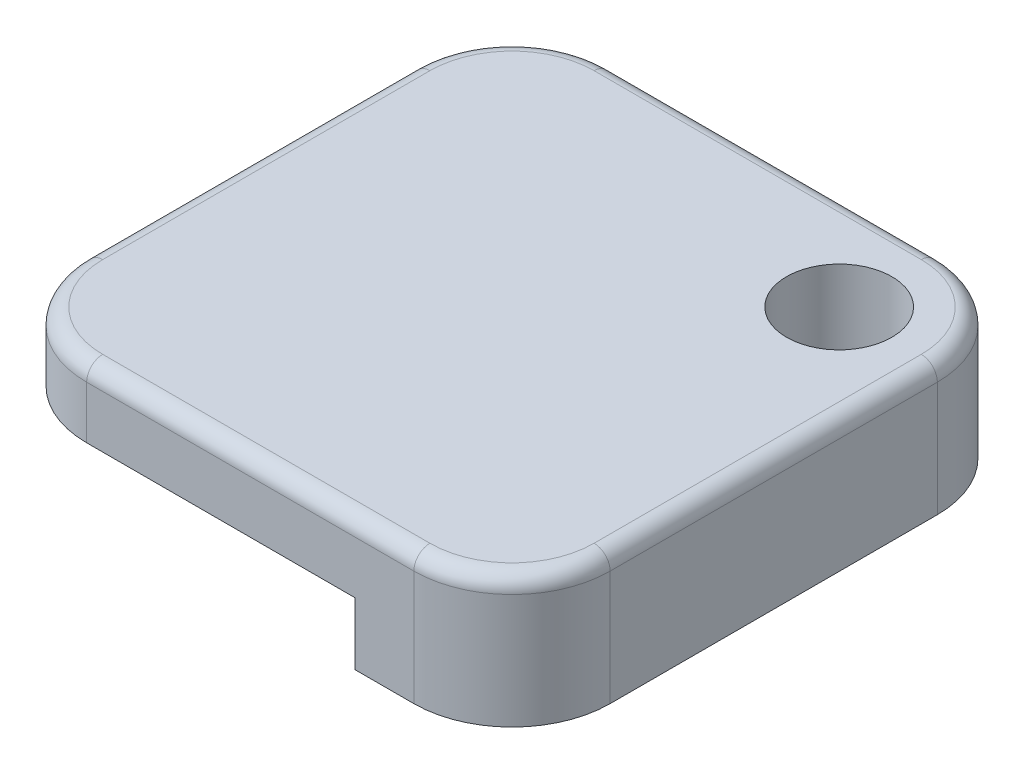
from build123d import *

# Parameters (mm, degrees)
SKETCH1_W                  = 25.4
SKETCH1_H                  = 25.4
BOSS_EXTRUDE1_DEPTH        = 6.35
SKETCH2_W                  = 17.78
SKETCH2_H                  = 17.78
CUT_EXTRUDE1_DEPTH         = 3.0226
FILLET1_R                  = 4.7625
F_10_CLEARANCE_HOLE1_D     = 5.1054
F_10_CLEARANCE_HOLE1_DEPTH = 10.668
F_10_CLEARANCE_HOLE1_TIP   = 1.533816902
FILLET2_R                  = 0.78


with BuildPart() as part:
    # Sketch1 → Boss-Extrude1 (new body)
    with BuildSketch(Plane(origin=(0, 0, 0), x_dir=(1, 0, 0), z_dir=(0, 1, 0))):
        Rectangle(SKETCH1_W, SKETCH1_H)
    extrude(amount=BOSS_EXTRUDE1_DEPTH)

    # Sketch2 → Cut-Extrude1 (cut)
    with BuildSketch(Plane.XZ):
        with Locations((-3.81, 3.81)):
            Rectangle(SKETCH2_W, SKETCH2_H)
    extrude(amount=-CUT_EXTRUDE1_DEPTH, mode=Mode.SUBTRACT)

    # Fillet1
    fillet1_edges = [part.edges().sort_by_distance(p)[0] for p in [
        (12.7, 3.175, 12.7),
        (-12.7, 4.6863, 12.7),
        (-12.7, 3.175, -12.7),
        (12.7, 3.175, -12.7),
    ]]
    fillet(fillet1_edges, radius=FILLET1_R)

    # #10 Clearance Hole1
    with Locations(Plane(origin=(0, 6.35, 0), x_dir=(1, 0, 0), z_dir=(0, 1, 0))):
        with Locations((7.9375, 7.9375)):
            Hole(F_10_CLEARANCE_HOLE1_D / 2, depth=F_10_CLEARANCE_HOLE1_DEPTH)
            with Locations((0, 0, -(F_10_CLEARANCE_HOLE1_DEPTH + F_10_CLEARANCE_HOLE1_TIP / 2))):  # 118° drill point
                Cone(0, F_10_CLEARANCE_HOLE1_D / 2, F_10_CLEARANCE_HOLE1_TIP, mode=Mode.SUBTRACT)

    # Fillet2
    fillet2_edges = [part.edges().sort_by_distance(p)[0] for p in [
        (0, 6.35, 12.7),
        (-12.7, 6.35, 0),
        (12.7, 6.35, 0),
        (0, 6.35, -12.7),
        (11.305096045, 6.35, 11.305096045),
        (11.305096045, 6.35, -11.305096045),
        (-11.305096045, 6.35, -11.305096045),
        (-11.305096045, 6.35, 11.305096045),
    ]]
    fillet(fillet2_edges, radius=FILLET2_R)


solid = part.part
